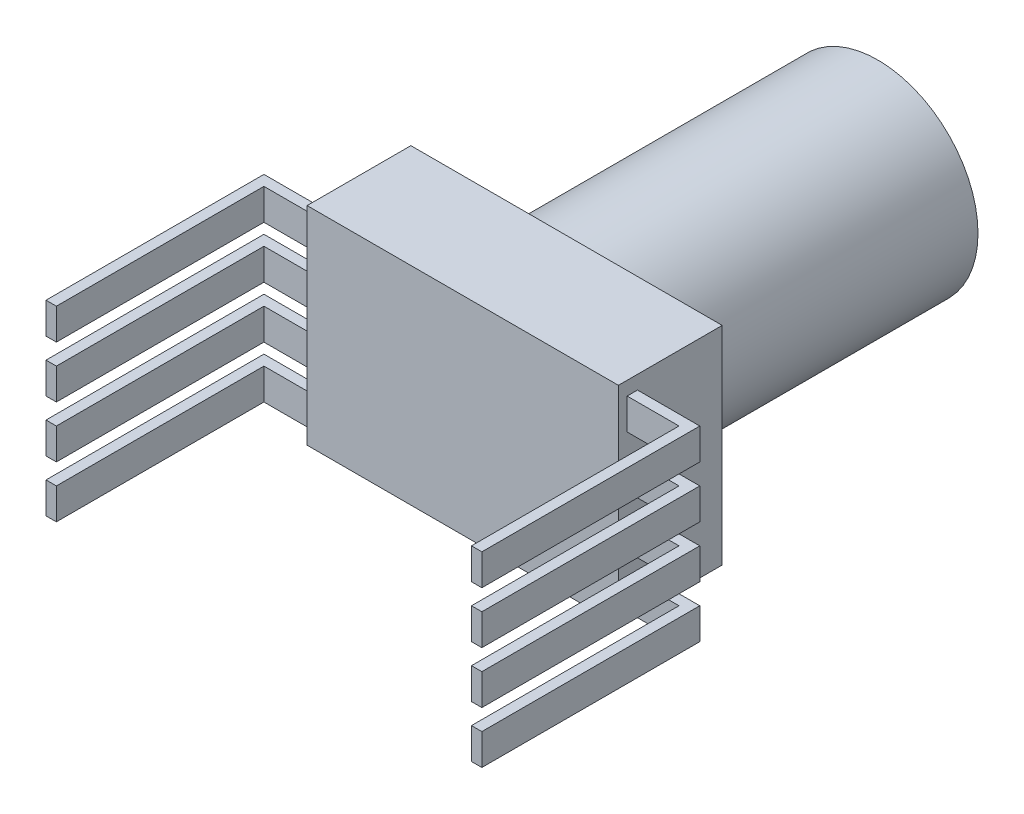
from build123d import *

# Parameters (mm, degrees)
SKETCH1_R               = 4.825
SKETCH1_R_2             = 1.818202682
BOSS_EXTRUDE1_DEPTH     = 15
SKETCH2_W               = 15
SKETCH2_H               = 10
BOSS_EXTRUDE2_DEPTH     = 5
SKETCH3_W               = 0.5
SKETCH3_H               = 1.5
BOSS_EXTRUDE3_DEPTH     = 3
SKETCH4_W               = 0.5
SKETCH4_H               = 1.5
BOSS_EXTRUDE4_DEPTH     = 10
LPATTERN2_COUNT         = 4
LPATTERN2_PITCH         = 2.5
MIRROR1_COPY_1_SKETCH_W = 0.5
MIRROR1_COPY_1_SKETCH_H = 1.5
MIRROR1_COPY_1_DEPTH    = 3
MIRROR1_COPY_2_SKETCH_W = 0.5
MIRROR1_COPY_2_SKETCH_H = 1.5
MIRROR1_COPY_2_DEPTH    = 3
MIRROR1_COPY_3_SKETCH_W = 0.5
MIRROR1_COPY_3_SKETCH_H = 1.5
MIRROR1_COPY_3_DEPTH    = 3
MIRROR1_COPY_4_SKETCH_W = 0.5
MIRROR1_COPY_4_SKETCH_H = 1.5
MIRROR1_COPY_4_DEPTH    = 10
MIRROR1_COPY_5_SKETCH_W = 0.5
MIRROR1_COPY_5_SKETCH_H = 1.5
MIRROR1_COPY_5_DEPTH    = 10
MIRROR1_COPY_6_SKETCH_W = 0.5
MIRROR1_COPY_6_SKETCH_H = 1.5
MIRROR1_COPY_6_DEPTH    = 10


with BuildPart() as part:
    # Sketch1 → Boss-Extrude1 (new body)
    with BuildSketch(Plane.XY):
        Circle(SKETCH1_R)
        Circle(SKETCH1_R_2, mode=Mode.SUBTRACT)
    extrude(amount=BOSS_EXTRUDE1_DEPTH)

    # Sketch2 → Boss-Extrude2 (add)
    with BuildSketch(Plane.XY.offset(15)):
        Rectangle(SKETCH2_W, SKETCH2_H)
    extrude(amount=BOSS_EXTRUDE2_DEPTH)

    # Sketch3 → Boss-Extrude3 (add)
    with BuildSketch(Plane.ZY.offset(7.5)):
        with Locations((19.330067801, 3.591756208)):
            Rectangle(SKETCH3_W, SKETCH3_H)
    boss_extrude3 = extrude(amount=BOSS_EXTRUDE3_DEPTH)

    # Sketch4 → Boss-Extrude4 (add)
    with BuildSketch(Plane.XY.offset(19.580067801)):
        with Locations((-10.25, 3.591756208)):
            Rectangle(SKETCH4_W, SKETCH4_H)
    boss_extrude4 = extrude(amount=BOSS_EXTRUDE4_DEPTH)

    # LPattern2: Boss-Extrude3, Boss-Extrude4 ×4
    with Locations(*[(0, -i * LPATTERN2_PITCH, 0) for i in range(1, LPATTERN2_COUNT)]):
        add(boss_extrude3)
        add(boss_extrude4)

    # Mirror1: Boss-Extrude3, Boss-Extrude4 across plane
    add(boss_extrude3.mirror(Plane(origin=(0, 0, 0), x_dir=(0, 0, 1), z_dir=(1, 0, 0))))
    add(boss_extrude4.mirror(Plane(origin=(0, 0, 0), x_dir=(0, 0, 1), z_dir=(1, 0, 0))))

    # Mirror1 copy 1 sketch → Mirror1 copy 1 (add)
    with BuildSketch(Plane(origin=(7.5, -2.5, 0), x_dir=(0, 0, 1), z_dir=(1, 0, 0))):
        with Locations((19.330067801, -3.591756208)):
            Rectangle(MIRROR1_COPY_1_SKETCH_W, MIRROR1_COPY_1_SKETCH_H)
    extrude(amount=MIRROR1_COPY_1_DEPTH)

    # Mirror1 copy 2 sketch → Mirror1 copy 2 (add)
    with BuildSketch(Plane(origin=(7.5, -5, 0), x_dir=(0, 0, 1), z_dir=(1, 0, 0))):
        with Locations((19.330067801, -3.591756208)):
            Rectangle(MIRROR1_COPY_2_SKETCH_W, MIRROR1_COPY_2_SKETCH_H)
    extrude(amount=MIRROR1_COPY_2_DEPTH)

    # Mirror1 copy 3 sketch → Mirror1 copy 3 (add)
    with BuildSketch(Plane(origin=(7.5, -7.5, 0), x_dir=(0, 0, 1), z_dir=(1, 0, 0))):
        with Locations((19.330067801, -3.591756208)):
            Rectangle(MIRROR1_COPY_3_SKETCH_W, MIRROR1_COPY_3_SKETCH_H)
    extrude(amount=MIRROR1_COPY_3_DEPTH)

    # Mirror1 copy 4 sketch → Mirror1 copy 4 (add)
    with BuildSketch(Plane(origin=(0, -2.5, 19.580067801), x_dir=(-1, 0, 0), z_dir=(0, 0, 1))):
        with Locations((-10.25, -3.591756208)):
            Rectangle(MIRROR1_COPY_4_SKETCH_W, MIRROR1_COPY_4_SKETCH_H)
    extrude(amount=MIRROR1_COPY_4_DEPTH)

    # Mirror1 copy 5 sketch → Mirror1 copy 5 (add)
    with BuildSketch(Plane(origin=(0, -5, 19.580067801), x_dir=(-1, 0, 0), z_dir=(0, 0, 1))):
        with Locations((-10.25, -3.591756208)):
            Rectangle(MIRROR1_COPY_5_SKETCH_W, MIRROR1_COPY_5_SKETCH_H)
    extrude(amount=MIRROR1_COPY_5_DEPTH)

    # Mirror1 copy 6 sketch → Mirror1 copy 6 (add)
    with BuildSketch(Plane(origin=(0, -7.5, 19.580067801), x_dir=(-1, 0, 0), z_dir=(0, 0, 1))):
        with Locations((-10.25, -3.591756208)):
            Rectangle(MIRROR1_COPY_6_SKETCH_W, MIRROR1_COPY_6_SKETCH_H)
    extrude(amount=MIRROR1_COPY_6_DEPTH)


solid = part.part
